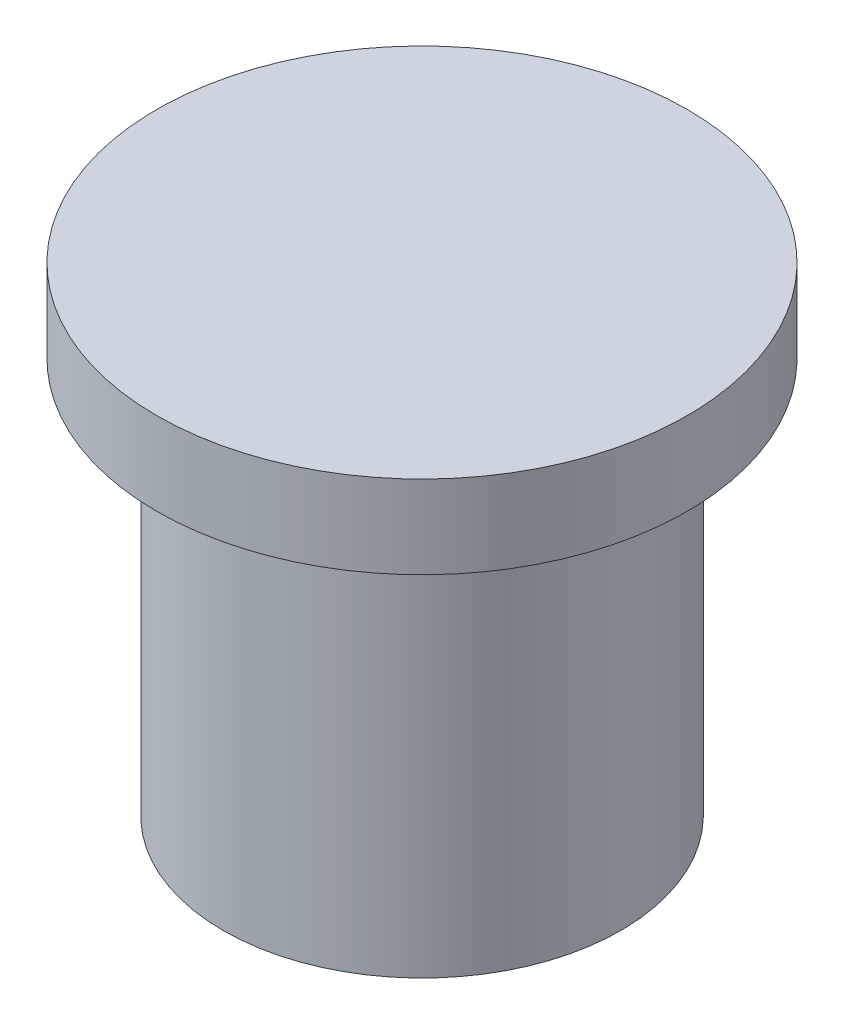
from build123d import *

# Parameters (mm, degrees)
SKETCH1_R           = 7.62
BOSS_EXTRUDE1_DEPTH = 15.175
SKETCH2_R           = 10.16
BOSS_EXTRUDE2_DEPTH = 3.175


with BuildPart() as part:
    # Sketch1 → Boss-Extrude1 (new body)
    with BuildSketch(Plane(origin=(0, 0, 0), x_dir=(1, 0, 0), z_dir=(0, 1, 0))):
        Circle(SKETCH1_R)
    extrude(amount=BOSS_EXTRUDE1_DEPTH)

    # Sketch2 → Boss-Extrude2 (add)
    with BuildSketch(Plane(origin=(0, 15.175, 0), x_dir=(1, 0, 0), z_dir=(0, 1, 0))):
        Circle(SKETCH2_R)
    extrude(amount=BOSS_EXTRUDE2_DEPTH)


solid = part.part
